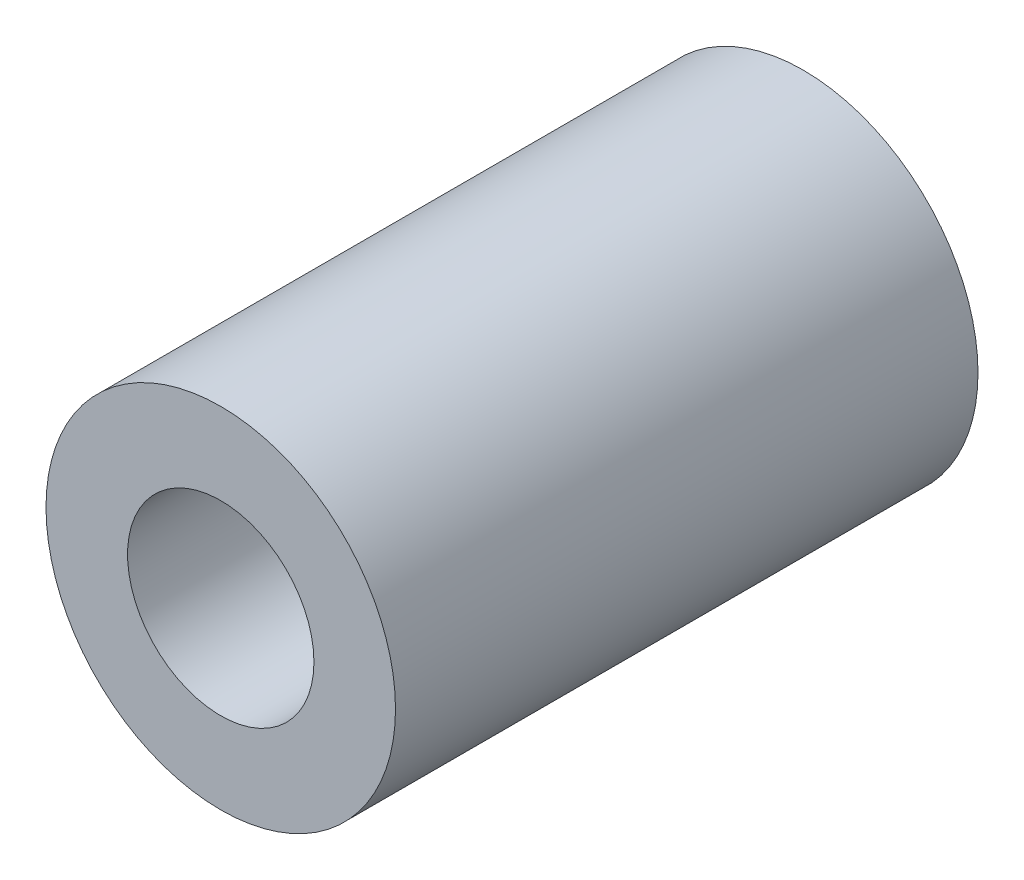
from build123d import *

# Parameters (mm, degrees)
SKETCH_1_R      = 3
SKETCH_1_R_2    = 1.6
EXTRUDE_1_DEPTH = 10


with BuildPart() as part:
    # ｽｹｯﾁ1 → ﾎﾞｽ - 押し出し1 (new body)
    with BuildSketch(Plane.XY):
        Circle(SKETCH_1_R)
        Circle(SKETCH_1_R_2, mode=Mode.SUBTRACT)
    extrude(amount=EXTRUDE_1_DEPTH)


solid = part.part
